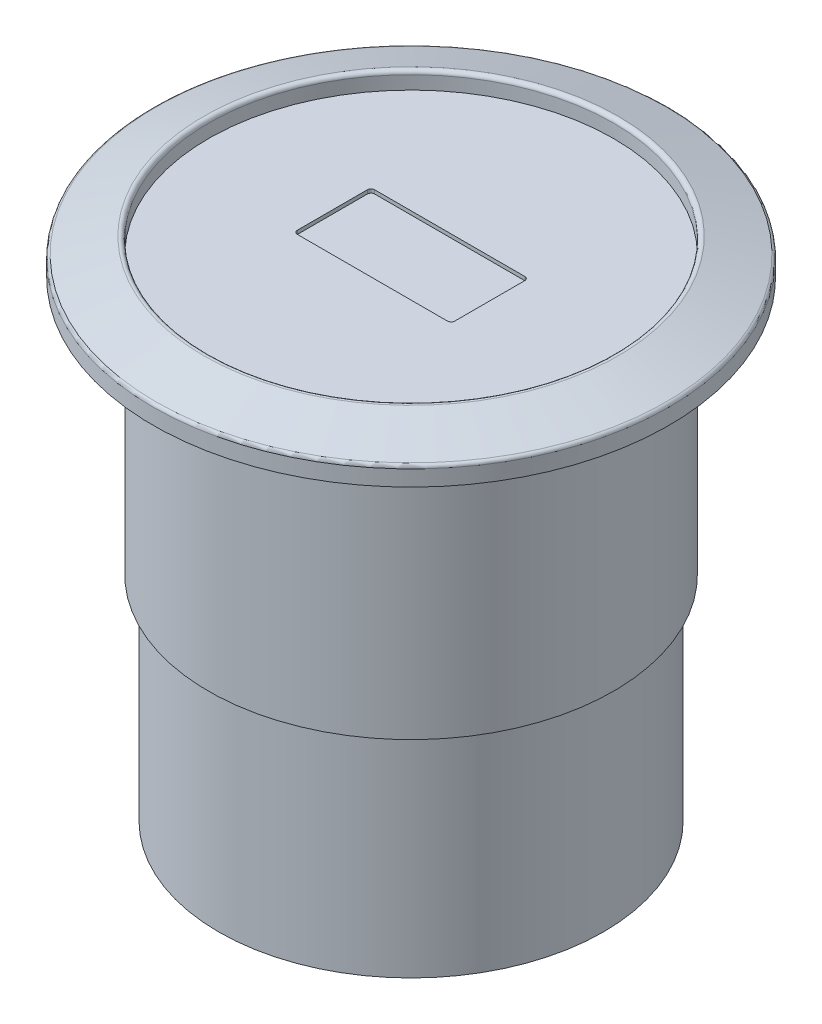
from build123d import *

# Parameters (mm, degrees)
FILLET1_R          = 0.2
SKETCH2_W          = 8.55
SKETCH2_H          = 4.2
CUT_EXTRUDE1_DEPTH = 0.2
FILLET2_R          = 0.2


with BuildPart() as part:
    # Sketch1 → Revolve1 (revolve)
    with BuildSketch(Plane.XY):
        Polygon((-11, 27.6), (-14, 26.6), (-14, 25.6), (-11, 25.6), (-11, 11.6), (-10.45, 11.6), (-10.45, 0), (0, 0), (0, 26.6), (-11, 26.6), align=None)
    revolve(axis=Axis((0, 0, 0), (0, 1, 0)))

    # Fillet1
    fillet1_edges = [part.edges().sort_by_distance(p)[0] for p in [
        (11, 27.6, 0),
        (14, 26.6, 0),
    ]]
    fillet(fillet1_edges, radius=FILLET1_R)

    # Sketch2 → Cut-Extrude1 (cut)
    with BuildSketch(Plane(origin=(0, 26.6, 0), x_dir=(1, 0, 0), z_dir=(0, 1, 0))):
        Rectangle(SKETCH2_W, SKETCH2_H)
    extrude(amount=-CUT_EXTRUDE1_DEPTH, mode=Mode.SUBTRACT)

    # Fillet2
    fillet2_edges = [part.edges().sort_by_distance(p)[0] for p in [
        (4.275, 26.5, 2.1),
        (-4.275, 26.5, 2.1),
        (-4.275, 26.5, -2.1),
        (4.275, 26.5, -2.1),
    ]]
    fillet(fillet2_edges, radius=FILLET2_R)


solid = part.part
